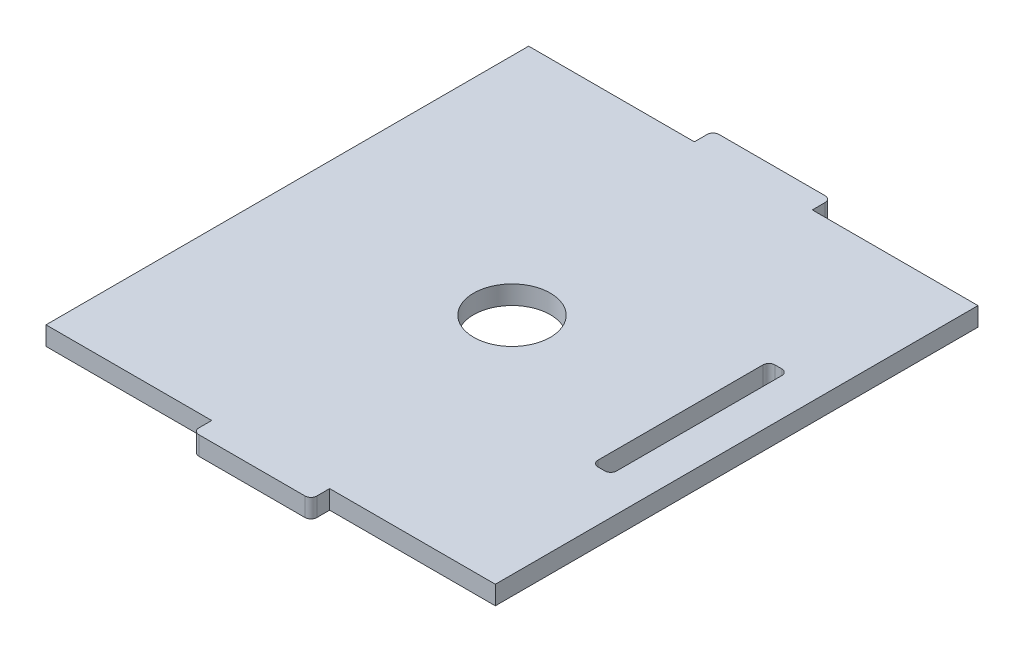
from build123d import *

# Parameters (mm, degrees)
BOSS_EXTRUDE1_DEPTH = 3.175
SKETCH2_R           = 6.5
SKETCH2_W           = 3.175
SKETCH2_H           = 30
CUT_EXTRUDE1_DEPTH  = 4.175
FILLET1_R           = 1


with BuildPart() as part:
    # Sketch1 → Boss-Extrude1 (new body)
    with BuildSketch(Plane(origin=(0, 0, 0), x_dir=(1, 0, 0), z_dir=(0, 1, 0))):
        Polygon((-38.1, -40.925), (-10, -40.925), (-10, -44.1), (10, -44.1), (10, -40.925), (38.1, -40.925), (38.1, 40.925), (10, 40.925), (10, 44.1), (-10, 44.1), (-10, 40.925), (-38.1, 40.925), align=None)
    extrude(amount=BOSS_EXTRUDE1_DEPTH)

    # Sketch2 → Cut-Extrude1 (cut, through all)
    with BuildSketch(Plane(origin=(0, 3.175, 0), x_dir=(1, 0, 0), z_dir=(0, 1, 0))):
        Circle(SKETCH2_R)
        with Locations((30.1625, 0)):
            Rectangle(SKETCH2_W, SKETCH2_H)
    extrude(amount=-CUT_EXTRUDE1_DEPTH, mode=Mode.SUBTRACT)

    # Fillet1
    fillet1_edges = [part.edges().sort_by_distance(p)[0] for p in [
        (10, 1.5875, 44.1),
        (-10, 1.5875, 44.1),
        (-10, 1.5875, -44.1),
        (10, 1.5875, -44.1),
        (28.575, 1.5875, 15),
        (28.575, 1.5875, -15),
        (31.75, 1.5875, -15),
        (31.75, 1.5875, 15),
    ]]
    fillet(fillet1_edges, radius=FILLET1_R)


solid = part.part
